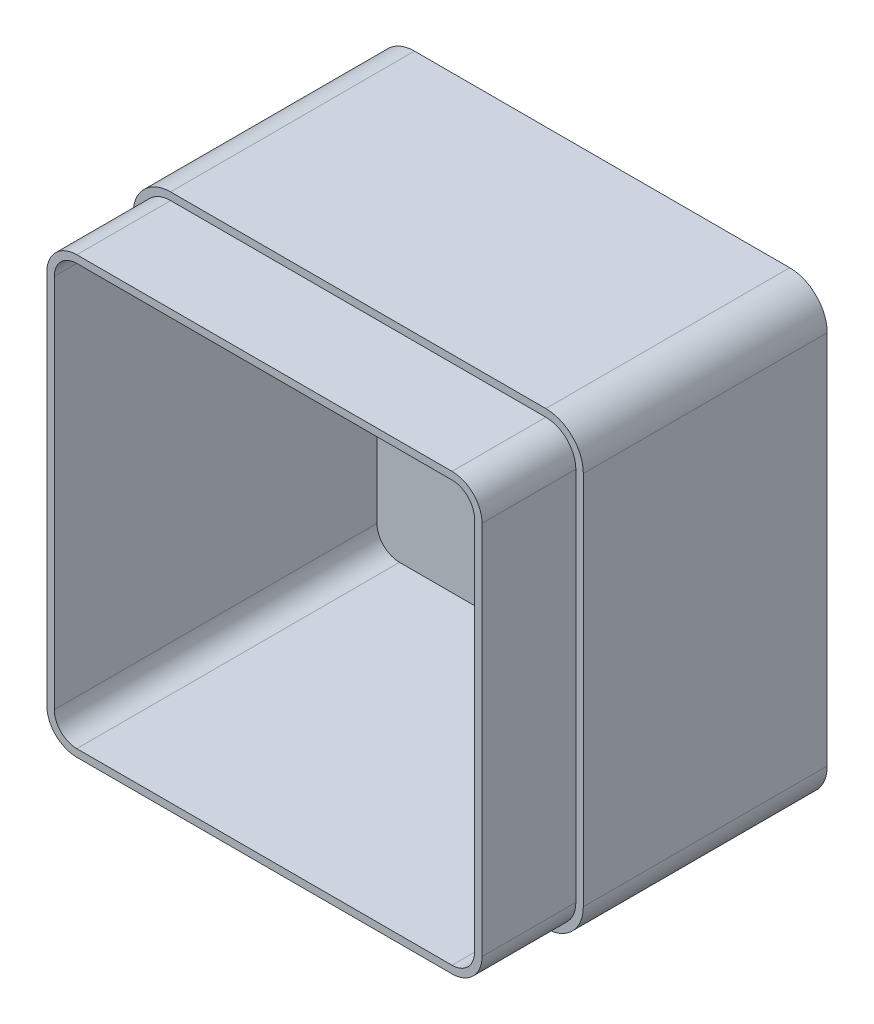
from build123d import *

# Parameters (mm, degrees)
CROQUIS1_W              = 120
CROQUIS1_H              = 120
SALIENTE_EXTRUIR1_DEPTH = 90
REDONDEO2_R             = 10
VACIADO1_T              = -4
CROQUIS6_OUTSIDE_W      = 160.418
CROQUIS6_OUTSIDE_H      = 160.418
CORTAR_EXTRUIR2_DEPTH   = 25


with BuildPart() as part:
    # Croquis1 → Saliente-Extruir1 (new body)
    with BuildSketch(Plane.XY):
        with Locations((60, 60)):
            Rectangle(CROQUIS1_W, CROQUIS1_H)
    extrude(amount=SALIENTE_EXTRUIR1_DEPTH)

    # Redondeo2
    redondeo2_edges = [part.edges().sort_by_distance(p)[0] for p in [
        (0, 120, 45),
        (120, 120, 45),
        (120, 0, 45),
        (0, 0, 45),
    ]]
    fillet(redondeo2_edges, radius=REDONDEO2_R)

    # Vaciado1
    vaciado1_openings = [part.faces().sort_by_distance(p)[0] for p in [
        (60, 60, 90),
    ]]
    offset(amount=VACIADO1_T, openings=vaciado1_openings, kind=Kind.INTERSECTION)

    # Croquis6 outside → Cortar-Extruir2 (cut)
    with BuildSketch(Plane.XY.offset(90)):
        with Locations((60, 60)):
            Rectangle(CROQUIS6_OUTSIDE_W, CROQUIS6_OUTSIDE_H)
        with BuildLine():
            Line((10, 2), (110, 2))
            ThreePointArc((110, 2), (115.656854249, 4.343145751), (118, 10))
            Line((118, 10), (118, 110))
            ThreePointArc((118, 110), (115.656854249, 115.656854249), (110, 118))
            Line((110, 118), (10, 118))
            ThreePointArc((10, 118), (4.343145751, 115.656854249), (2, 110))
            Line((2, 110), (2, 10))
            ThreePointArc((2, 10), (4.343145751, 4.343145751), (10, 2))
        make_face(mode=Mode.SUBTRACT)
    extrude(amount=-CORTAR_EXTRUIR2_DEPTH, mode=Mode.SUBTRACT)


solid = part.part
